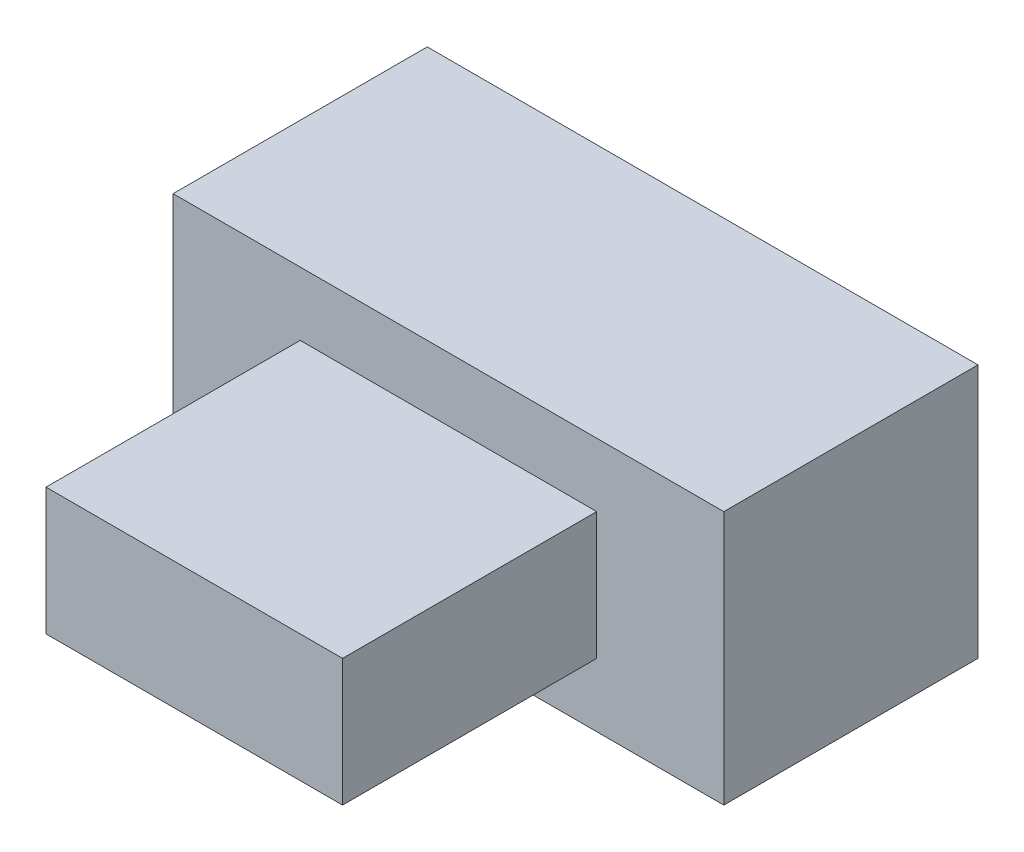
from build123d import *

# Parameters (mm, degrees)
SKETCH1_W           = 13
SKETCH1_H           = 6
BOSS_EXTRUDE1_DEPTH = 6
SKETCH2_W           = 7
SKETCH2_H           = 3
BOSS_EXTRUDE2_DEPTH = 6


with BuildPart() as part:
    # Sketch1 → Boss-Extrude1 (new body)
    with BuildSketch(Plane.XY):
        with Locations((6.5, 3)):
            Rectangle(SKETCH1_W, SKETCH1_H)
    extrude(amount=BOSS_EXTRUDE1_DEPTH)

    # Sketch2 → Boss-Extrude2 (add)
    with BuildSketch(Plane.XY.offset(6)):
        with Locations((6.5, 3)):
            Rectangle(SKETCH2_W, SKETCH2_H)
    extrude(amount=BOSS_EXTRUDE2_DEPTH)


solid = part.part
